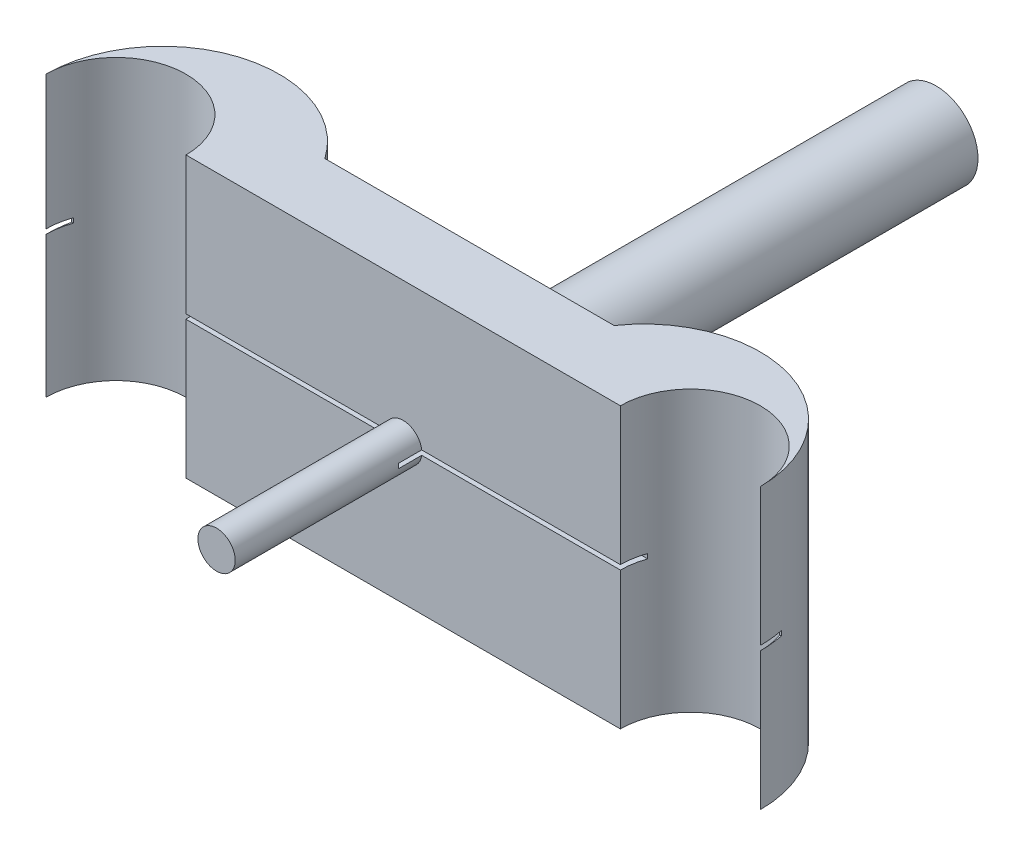
from build123d import *

# Parameters (mm, degrees)
BOSS_EXTRUDE1_DEPTH      = 30
SKETCH3_R                = 4.5
SKETCH3_R_2              = 2.5
BOSS_EXTRUDE3_DEPTH      = 50
CUT_EXTRUDE2_REACH       = 71.06
SKETCH7_R                = 1.5
SKETCH8_R                = 2
BOSS_EXTRUDE6_DEPTH      = 20
SKETCH9_W                = 5
SKETCH9_H                = 0.5
CUT_EXTRUDE14_DEPTH      = 15
SKETCH11_W               = 5
SKETCH11_H               = 0.5
CUT_EXTRUDE16_DEPTH      = 1
CUT_EXTRUDE16_DEPTH_BACK = 4
FILLET1_R                = 0.5
SKETCH10_W               = 5
SKETCH10_H               = 0.5
CUT_EXTRUDE15_DEPTH      = 107.779594


with BuildPart() as part:
    # Sketch1 → Boss-Extrude1 (new body)
    with BuildSketch(Plane(origin=(0, 0, 0), x_dir=(1, 0, 0), z_dir=(0, 1, 0))):
        with BuildLine():
            Line((15.281403332, 7.10934213), (46.278596668, 7.10934213))
            ThreePointArc((46.278596668, 7.10934213), (60.283738602, 11.932467089), (69.06, 0))
            ThreePointArc((69.06, 0), (61.56, 7.5), (54.06, 0))
            Line((54.06, 0), (7.5, 0))
            ThreePointArc((7.5, 0), (0, 7.5), (-7.5, 0))
            ThreePointArc((-7.5, 0), (1.276261398, 11.932467089), (15.281403332, 7.10934213))
        make_face()
    extrude(amount=BOSS_EXTRUDE1_DEPTH)

    # Sketch3 → Boss-Extrude3 (add)
    with BuildSketch(Plane(origin=(0, 0, -7.10934213), x_dir=(-1, 0, 0), z_dir=(0, 0, -1))):
        with Locations((-30.78, 15)):
            Circle(SKETCH3_R)
        with Locations((-30.78, 15)):
            Circle(SKETCH3_R_2, mode=Mode.SUBTRACT)
    extrude(amount=BOSS_EXTRUDE3_DEPTH)

    # Sketch7 → Cut-Extrude2 (cut, up to next)
    with BuildSketch(Plane(origin=(0, 0, 0), x_dir=(0, 0, -1), z_dir=(1, 0, 0)), mode=Mode.PRIVATE) as cut_extrude2_sk1:
        with Locations((53.042344304, 15)):
            Circle(SKETCH7_R)
    cut_extrude2_tool1 = extrude(cut_extrude2_sk1.sketch, amount=CUT_EXTRUDE2_REACH, mode=Mode.PRIVATE) & part.part
    add(cut_extrude2_tool1.solids().sort_by_distance((0, 15, -53.042344))[0], mode=Mode.SUBTRACT)

    # Sketch8 → Boss-Extrude6 (add)
    with BuildSketch(Plane.XY):
        with Locations((30.78, 15)):
            Circle(SKETCH8_R)
    extrude(amount=BOSS_EXTRUDE6_DEPTH)

    # Sketch9 → Cut-Extrude14 (cut)
    with BuildSketch(Plane(origin=(0, 0, 0), x_dir=(0, 0, -1), z_dir=(1, 0, 0))):
        with Locations((0, 15.381990369)):
            Rectangle(SKETCH9_W, SKETCH9_H)
    extrude(amount=-CUT_EXTRUDE14_DEPTH, mode=Mode.SUBTRACT)

    # Sketch11 → Cut-Extrude16 (cut, two sides)
    with BuildSketch(Plane(origin=(68.252070678, 0, 0), x_dir=(0, 0, -1), z_dir=(-1, 0, 0))) as cut_extrude16_sk:
        with Locations((0, -15)):
            Rectangle(SKETCH11_W, SKETCH11_H)
    extrude(amount=CUT_EXTRUDE16_DEPTH, mode=Mode.SUBTRACT)
    extrude(cut_extrude16_sk.sketch, amount=-CUT_EXTRUDE16_DEPTH_BACK, mode=Mode.SUBTRACT)

    # Fillet1
    fillet1_edges = [part.edges().sort_by_distance(p)[0] for p in [
        (35.28, 15, -7.10934213),
    ]]
    fillet(fillet1_edges, radius=FILLET1_R)

    # Sketch10 → Cut-Extrude15 (cut)
    with BuildSketch(Plane(origin=(0, 0, 0), x_dir=(0, 0, -1), z_dir=(1, 0, 0))):
        with Locations((0, 15)):
            Rectangle(SKETCH10_W, SKETCH10_H)
    extrude(amount=CUT_EXTRUDE15_DEPTH, mode=Mode.SUBTRACT)


solid = part.part
